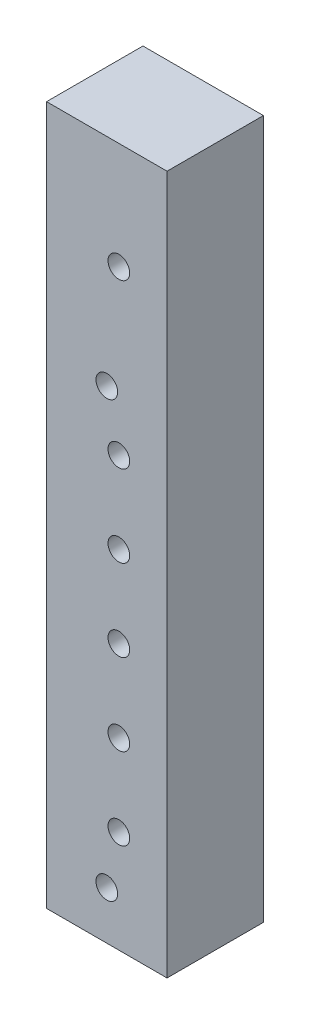
from build123d import *

# Parameters (mm, degrees)
SKETCH_1_W      = 15
SKETCH_1_H      = 87
SKETCH_1_R      = 1.35
EXTRUDE_1_DEPTH = 12


with BuildPart() as part:
    # 草圖1 → 填料-伸長1 (new body)
    with BuildSketch(Plane(origin=(0, 0, -6), x_dir=(-1, 0, 0), z_dir=(0, 0, -1))):
        with Locations((0, 43.5)):
            Rectangle(SKETCH_1_W, SKETCH_1_H)
        with Locations((-1.5, 22.89)):
            Circle(SKETCH_1_R, mode=Mode.SUBTRACT)
        with Locations((-1.5, 43.21)):
            Circle(SKETCH_1_R, mode=Mode.SUBTRACT)
        with Locations((0, 60.1)):
            Circle(SKETCH_1_R, mode=Mode.SUBTRACT)
        with Locations((0, 6)):
            Circle(SKETCH_1_R, mode=Mode.SUBTRACT)
        with Locations((-1.5, 12.73)):
            Circle(SKETCH_1_R, mode=Mode.SUBTRACT)
        with Locations((-1.5, 33.05)):
            Circle(SKETCH_1_R, mode=Mode.SUBTRACT)
        with Locations((-1.5, 53.37)):
            Circle(SKETCH_1_R, mode=Mode.SUBTRACT)
        with Locations((-1.5, 73.69)):
            Circle(SKETCH_1_R, mode=Mode.SUBTRACT)
    extrude(amount=-EXTRUDE_1_DEPTH)


solid = part.part
